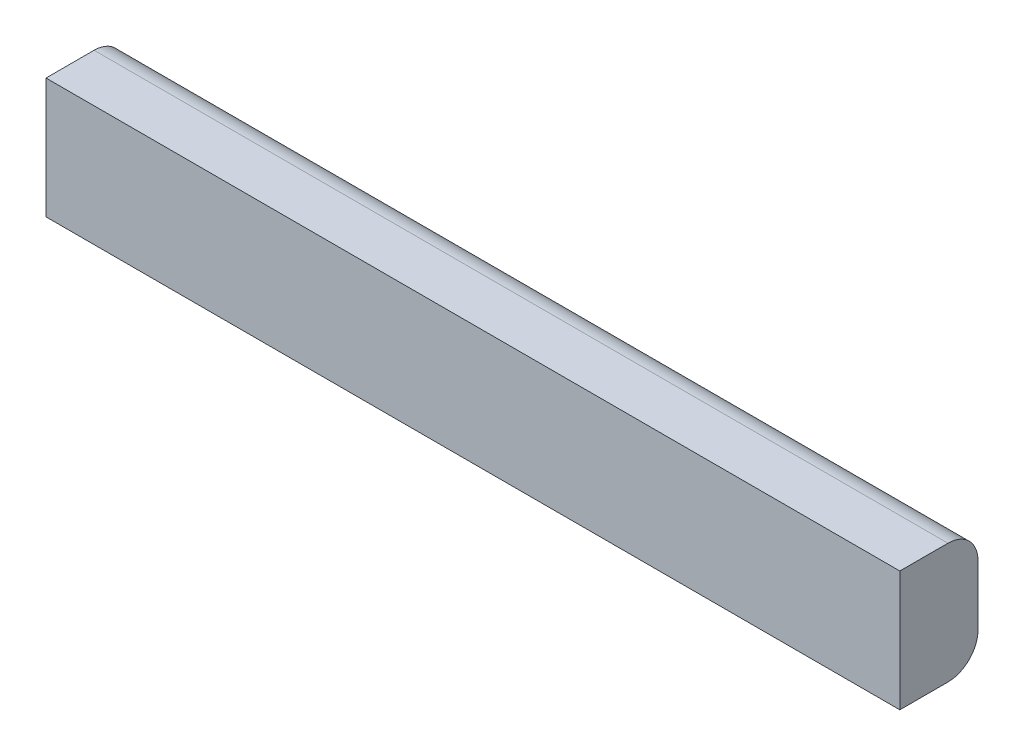
from build123d import *

# Parameters (mm, degrees)
BOSS_EXTRUDE1_DEPTH = 450.85


with BuildPart() as part:
    # Sketch1 → Boss-Extrude1 (new body, symmetric)
    with BuildSketch(Plane(origin=(0, 0, 0), x_dir=(0, 0, -1), z_dir=(1, 0, 0))):
        with BuildLine():
            Line((49.373646209, 66.02166065), (-1.426353791, 66.02166065))
            Line((-1.426353791, 66.02166065), (-1.426353791, -60.97833935))
            Line((-1.426353791, -60.97833935), (49.373646209, -60.97833935))
            ThreePointArc((49.373646209, -60.97833935), (71.824286512, -51.678979653), (81.123646209, -29.22833935))
            Line((81.123646209, -29.22833935), (81.123646209, 34.27166065))
            ThreePointArc((81.123646209, 34.27166065), (71.824286512, 56.722300952), (49.373646209, 66.02166065))
        make_face()
    extrude(amount=BOSS_EXTRUDE1_DEPTH, both=True)


solid = part.part
